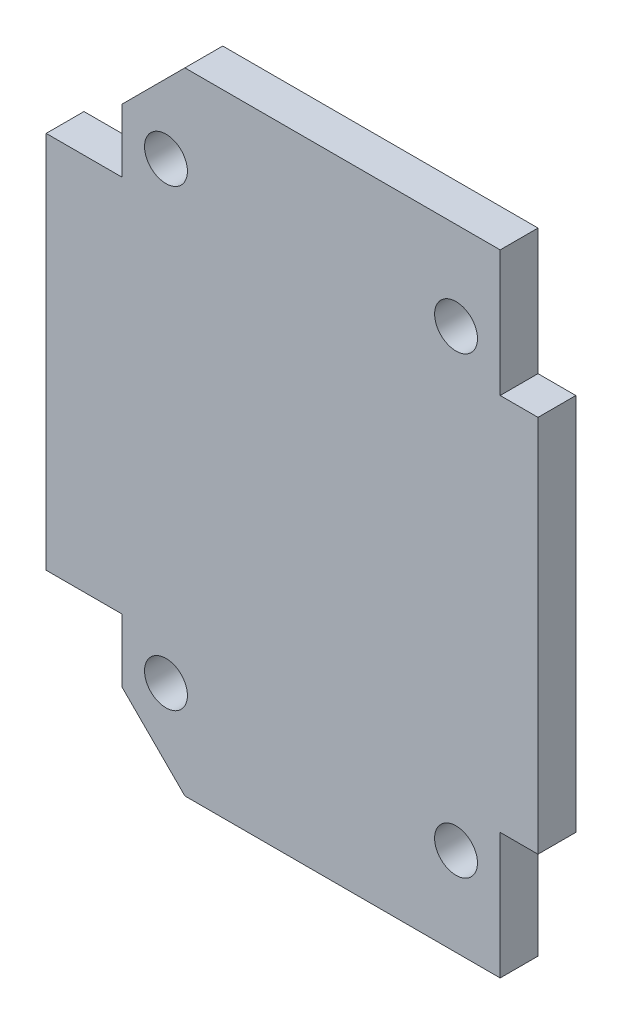
from build123d import *

# Parameters (mm, degrees)
SKETCH1_R           = 1.7
BOSS_EXTRUDE1_DEPTH = 3
CHAMFER1_SIZE       = 5


with BuildPart() as part:
    # Sketch1 → Boss-Extrude1 (new body)
    with BuildSketch(Plane.XY):
        Polygon((-15, -25), (15, -25), (15, -15), (18, -15), (18, 15), (15, 15), (15, 25), (-15, 25), (-15, 15), (-21, 15), (-21, -15), (-15, -15), align=None)
        with Locations((11.5, -18)):
            Circle(SKETCH1_R, mode=Mode.SUBTRACT)
        with Locations((11.5, 18)):
            Circle(SKETCH1_R, mode=Mode.SUBTRACT)
        with Locations((-11.5, 18)):
            Circle(SKETCH1_R, mode=Mode.SUBTRACT)
        with Locations((-11.5, -18)):
            Circle(SKETCH1_R, mode=Mode.SUBTRACT)
    extrude(amount=BOSS_EXTRUDE1_DEPTH)

    # Chamfer1
    chamfer1_edges = [part.edges().sort_by_distance(p)[0] for p in [
        (-15, -25, 1.5),
        (-15, 25, 1.5),
    ]]
    chamfer(chamfer1_edges, length=CHAMFER1_SIZE)


solid = part.part
